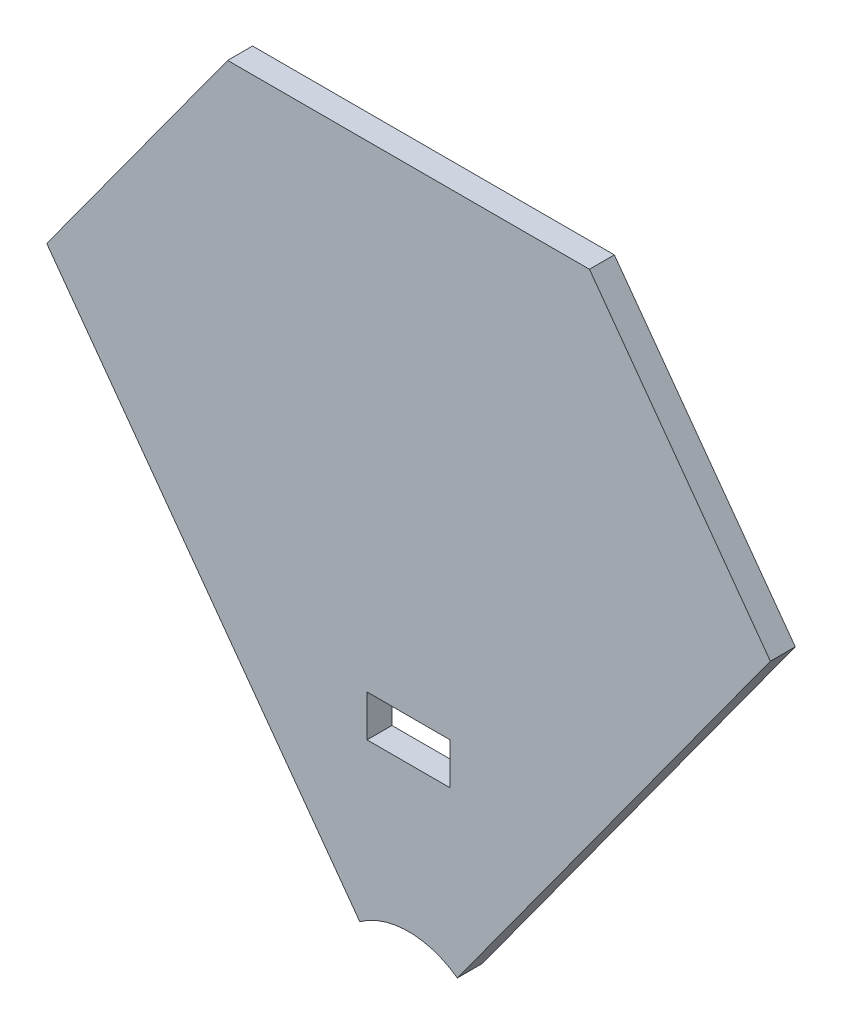
from build123d import *

# Parameters (mm, degrees)
SKETCH3_W           = 10
SKETCH3_H           = 5
BOSS_EXTRUDE1_DEPTH = 3
BOSS_EXTRUDE2_DEPTH = 3
CUT_EXTRUDE1_DEPTH  = 4
SKETCH6_R           = 10
CUT_EXTRUDE2_DEPTH  = 4


with BuildPart() as part:
    # Sketch3 → Boss-Extrude1 (new body)
    with BuildSketch(Plane.XY):
        Polygon((0, 0), (54.4906896, 75), (-54.4906896, 75), align=None)
        with Locations((0, 30)):
            Rectangle(SKETCH3_W, SKETCH3_H, mode=Mode.SUBTRACT)
    extrude(amount=BOSS_EXTRUDE1_DEPTH)

    # Sketch4 → Boss-Extrude2 (add)
    with BuildSketch(Plane(origin=(0, 0, 0), x_dir=(-1, 0, 0), z_dir=(0, 0, -1))):
        Polygon((-54.4906896, 75), (-65.38882752, 90), (65.38882752, 90), (54.4906896, 75), align=None)
    extrude(amount=-BOSS_EXTRUDE2_DEPTH)

    # Sketch5 → Cut-Extrude1 (cut, through all)
    with BuildSketch(Plane.XY.offset(3)):
        Polygon((-65.38882752, 90), (-21.79627584, 90), (-43.59255168, 60), align=None)
        Polygon((65.38882752, 90), (21.79627584, 90), (43.59255168, 60), align=None)
    extrude(amount=-CUT_EXTRUDE1_DEPTH, mode=Mode.SUBTRACT)

    # Sketch6 → Cut-Extrude2 (cut, through all)
    with BuildSketch(Plane(origin=(0, 0, 0), x_dir=(-1, 0, 0), z_dir=(0, 0, -1))):
        Circle(SKETCH6_R)
    extrude(amount=-CUT_EXTRUDE2_DEPTH, mode=Mode.SUBTRACT)


solid = part.part
